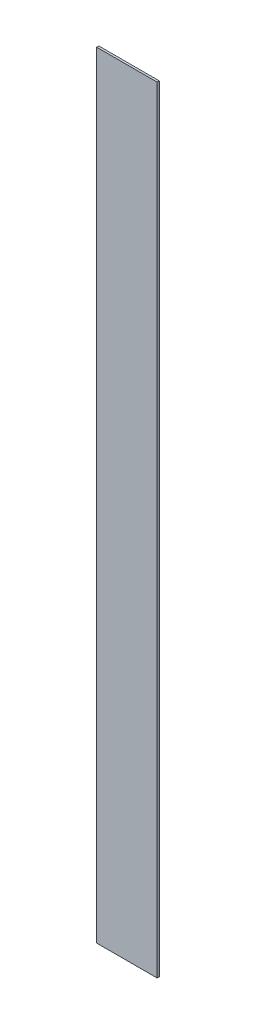
from build123d import *

# Parameters (mm, degrees)
SKETCH2_W           = 140
SKETCH2_H           = 1800
BOSS_EXTRUDE1_DEPTH = 5


with BuildPart() as part:
    # Sketch2 → Boss-Extrude1 (new body)
    with BuildSketch(Plane.XY):
        Rectangle(SKETCH2_W, SKETCH2_H)
    extrude(amount=BOSS_EXTRUDE1_DEPTH)


solid = part.part
